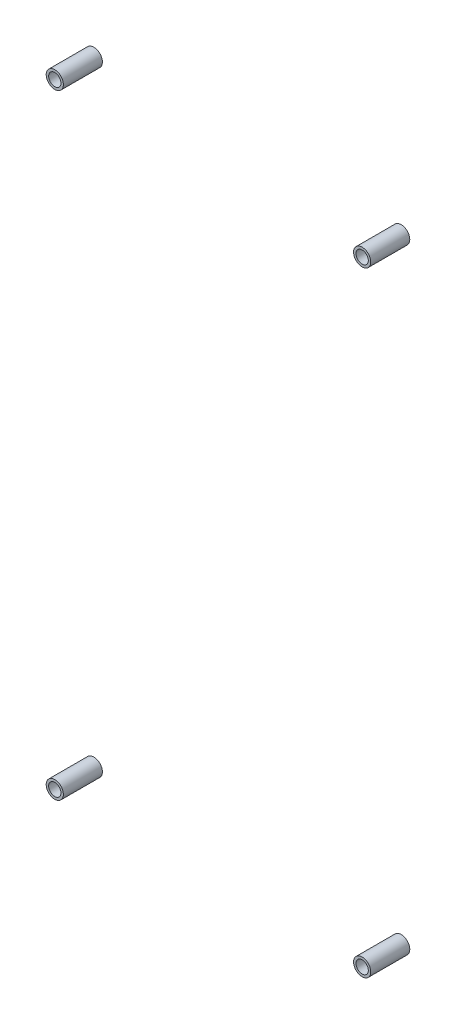
from build123d import *

# Parameters (mm, degrees)
SKETCH1_R             = 2.234999975
SKETCH1_R_2           = 1.599999975
BOSS_EXTRUDE1_DEPTH   = 10.16
BOSS_EXTRUDE1_2_DEPTH = 10.16
BOSS_EXTRUDE1_3_DEPTH = 10.16
BOSS_EXTRUDE1_4_DEPTH = 10.16


with BuildPart() as part:
    # Sketch1 → Boss-Extrude1 (new body)
    with BuildSketch(Plane.XY):
        with Locations((-116.2, 180.34)):
            Circle(SKETCH1_R)
        with Locations((-116.2, 180.34)):
            Circle(SKETCH1_R_2, mode=Mode.SUBTRACT)
    extrude(amount=BOSS_EXTRUDE1_DEPTH)


with BuildPart() as body_2:
    # Sketch1 → Boss-Extrude1 2 (new body)
    with BuildSketch(Plane.XY):
        with Locations((-36.2, 180.34)):
            Circle(SKETCH1_R)
        with Locations((-36.2, 180.34)):
            Circle(SKETCH1_R_2, mode=Mode.SUBTRACT)
    extrude(amount=BOSS_EXTRUDE1_2_DEPTH)


with BuildPart() as body_3:
    # Sketch1 → Boss-Extrude1 3 (new body)
    with BuildSketch(Plane.XY):
        with Locations((-116.2, 20.34)):
            Circle(SKETCH1_R)
        with Locations((-116.2, 20.34)):
            Circle(SKETCH1_R_2, mode=Mode.SUBTRACT)
    extrude(amount=BOSS_EXTRUDE1_3_DEPTH)


with BuildPart() as body_4:
    # Sketch1 → Boss-Extrude1 4 (new body)
    with BuildSketch(Plane.XY):
        with Locations((-36.2, 20.34)):
            Circle(SKETCH1_R)
        with Locations((-36.2, 20.34)):
            Circle(SKETCH1_R_2, mode=Mode.SUBTRACT)
    extrude(amount=BOSS_EXTRUDE1_4_DEPTH)


solid = Compound([part.part, body_2.part, body_3.part, body_4.part])
